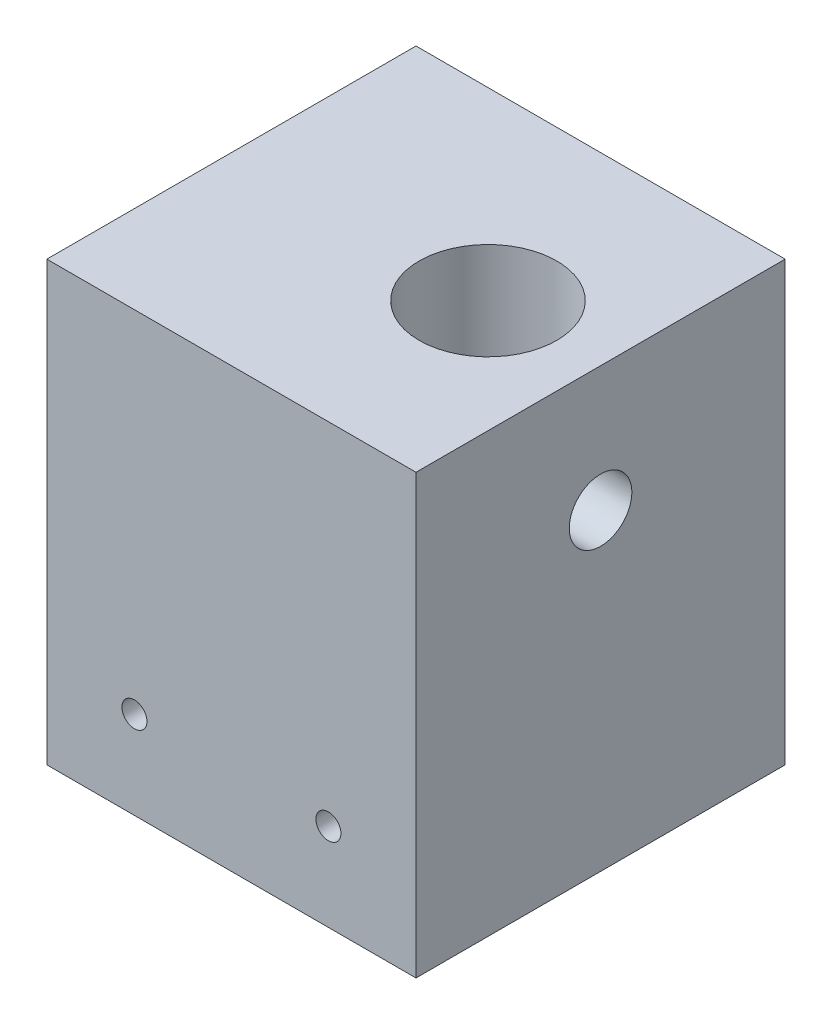
from build123d import *

# Parameters (mm, degrees)
ESQUISSE1_W             = 59
ESQUISSE1_H             = 59
BOSS_EXTRU_1_DEPTH      = 70
ENL_V_MAT_EXTRU_1_REACH = 61
ESQUISSE2_R             = 2
ESQUISSE3_R             = 11
ENL_V_MAT_EXTRU_2_DEPTH = 25
ENL_V_MAT_EXTRU_3_REACH = 61
ESQUISSE4_R             = 5


with BuildPart() as part:
    # Esquisse1 → Boss.-Extru.1 (new body)
    with BuildSketch(Plane(origin=(0, 0, 0), x_dir=(1, 0, 0), z_dir=(0, 1, 0))):
        with Locations((0.20896915, -12.058522539)):
            Rectangle(ESQUISSE1_W, ESQUISSE1_H)
    extrude(amount=BOSS_EXTRU_1_DEPTH)

    # Esquisse2 → Enlèv. mat.-Extru.1 (cut, up to next)
    with BuildSketch(Plane.XY.offset(41.558522539), mode=Mode.PRIVATE) as enl_v_mat_extru_1_sk1:
        with Locations((-15.29103085, 14)):
            Circle(ESQUISSE2_R)
    enl_v_mat_extru_1_tool1 = extrude(enl_v_mat_extru_1_sk1.sketch, amount=-ENL_V_MAT_EXTRU_1_REACH, mode=Mode.PRIVATE) & part.part
    add(enl_v_mat_extru_1_tool1.solids().sort_by_distance((-15.291031, 14, 41.558523))[0], mode=Mode.SUBTRACT)
    # Esquisse2 → Enlèv. mat.-Extru.1 (cut, up to next)
    with BuildSketch(Plane.XY.offset(41.558522539), mode=Mode.PRIVATE) as enl_v_mat_extru_1_sk2:
        with Locations((15.70896915, 14)):
            Circle(ESQUISSE2_R)
    enl_v_mat_extru_1_tool2 = extrude(enl_v_mat_extru_1_sk2.sketch, amount=-ENL_V_MAT_EXTRU_1_REACH, mode=Mode.PRIVATE) & part.part
    add(enl_v_mat_extru_1_tool2.solids().sort_by_distance((15.708969, 14, 41.558523))[0], mode=Mode.SUBTRACT)

    # Esquisse3 → Enlèv. mat.-Extru.2 (cut)
    with BuildSketch(Plane(origin=(0, 70, 0), x_dir=(1, 0, 0), z_dir=(0, 1, 0))):
        with Locations((11.70896915, -12.058522539)):
            Circle(ESQUISSE3_R)
    extrude(amount=-ENL_V_MAT_EXTRU_2_DEPTH, mode=Mode.SUBTRACT)

    # Esquisse4 → Enlèv. mat.-Extru.3 (cut, up to next)
    with BuildSketch(Plane(origin=(29.70896915, 0, 0), x_dir=(0, 0, -1), z_dir=(1, 0, 0)), mode=Mode.PRIVATE) as enl_v_mat_extru_3_sk1:
        with Locations((-12.058522539, 50)):
            Circle(ESQUISSE4_R)
    enl_v_mat_extru_3_tool1 = extrude(enl_v_mat_extru_3_sk1.sketch, amount=-ENL_V_MAT_EXTRU_3_REACH, mode=Mode.PRIVATE) & part.part
    add(enl_v_mat_extru_3_tool1.solids().sort_by_distance((29.708969, 50, 12.058523))[0], mode=Mode.SUBTRACT)


solid = part.part
